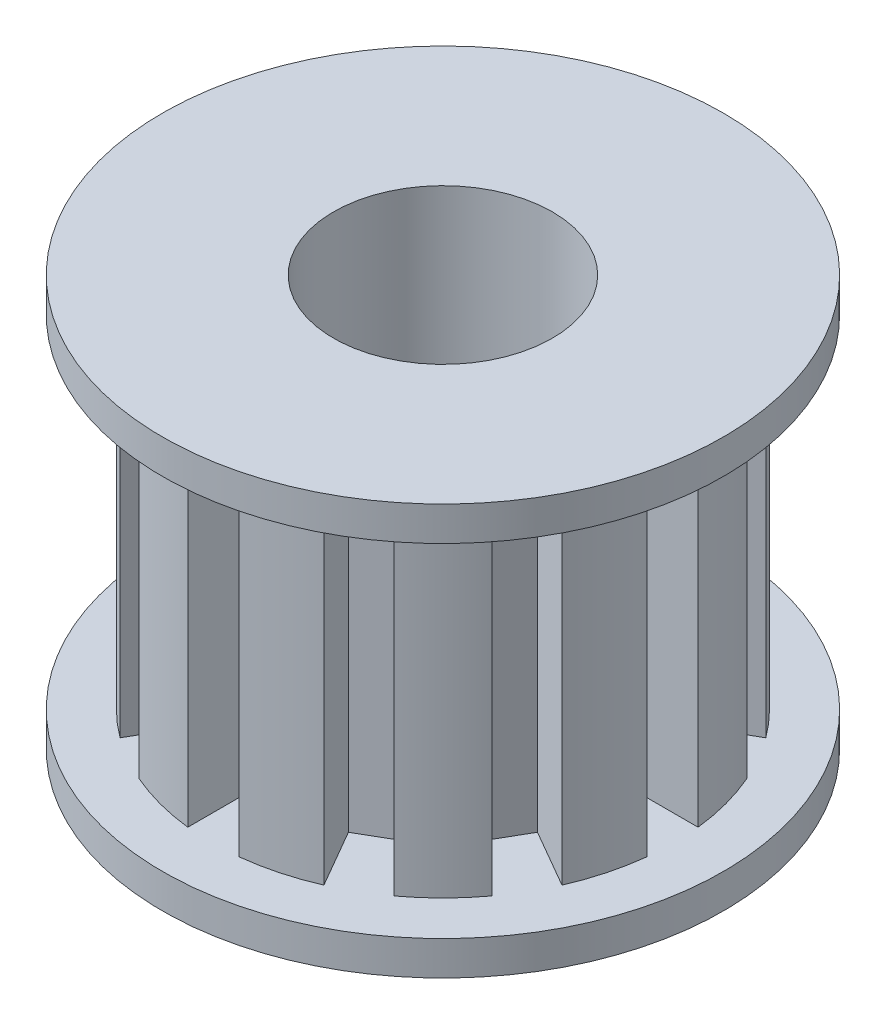
from build123d import *

# Parameters (mm, degrees)
SKETCH3_W          = 1.5
SKETCH3_H          = 10
CUT_EXTRUDE1_DEPTH = 2
CIRPATTERN1_COUNT  = 12


with BuildPart() as part:
    # Sketch1 → Revolve1 (revolve)
    with BuildSketch(Plane.XY, mode=Mode.PRIVATE) as revolve1_sk:
        Polygon((3.2, 8.917647059), (6.75, 8.917647059), (8.2, 8.917647059), (8.2, 7.917647059), (6.75, 7.917647059), (6.75, -2.082352941), (8.2, -2.082352941), (8.2, -3.082352941), (6.75, -3.082352941), (3.2, -3.082352941), align=None)
    revolve(revolve1_sk.sketch.rotate(Axis((0, 0, 0), (0, 1, 0)), 90), axis=Axis((0, 0, 0), (0, 1, 0)))  # turned: the seam where the file's is

    # Sketch3 → Cut-Extrude1 (cut)
    with BuildSketch(Plane(origin=(0, 0, -6.75), x_dir=(-1, 0, 0), z_dir=(0, 0, -1))):
        with Locations((0, 2.917647059)):
            Rectangle(SKETCH3_W, SKETCH3_H)
    cut_extrude1 = extrude(amount=-CUT_EXTRUDE1_DEPTH, mode=Mode.SUBTRACT)

    # CirPattern1: Cut-Extrude1 ×12 about axis
    cirpattern1_axis = Axis((0, 0, 0), (0, 1, 0))
    for i in range(1, CIRPATTERN1_COUNT):
        add(cut_extrude1.rotate(cirpattern1_axis, i * 360 / CIRPATTERN1_COUNT), mode=Mode.SUBTRACT)


solid = part.part
